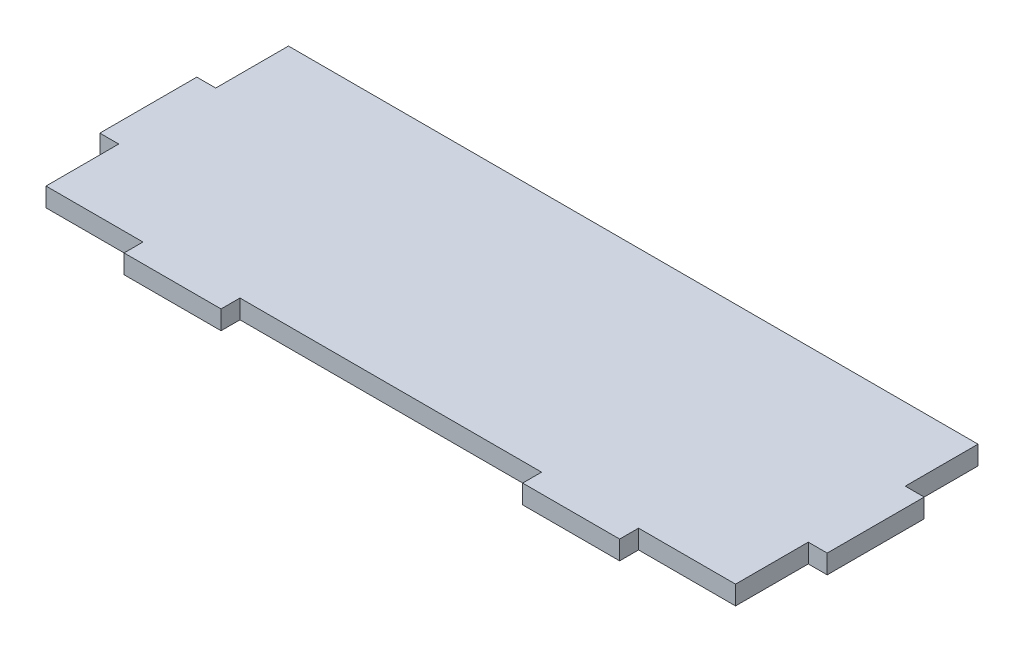
from build123d import *

# Parameters (mm, degrees)
BOSS_EXTRUDE1_DEPTH = 3.9


with BuildPart() as part:
    # Sketch1 → Boss-Extrude1 (new body)
    with BuildSketch(Plane(origin=(0, 0, 0), x_dir=(1, 0, 0), z_dir=(0, 1, 0))):
        Polygon((-71.1, 25), (-71.1, 10), (-75, 10), (-75, -10), (-71.1, -10), (-71.1, -25), (-51.1, -25), (-51.1, -28.9), (-31.1, -28.9), (-31.1, -25), (31.1, -25), (31.1, -28.9), (51.1, -28.9), (51.1, -25), (71.1, -25), (71.1, -10), (75, -10), (75, 10), (71.1, 10), (71.1, 25), align=None)
    extrude(amount=BOSS_EXTRUDE1_DEPTH)


solid = part.part
